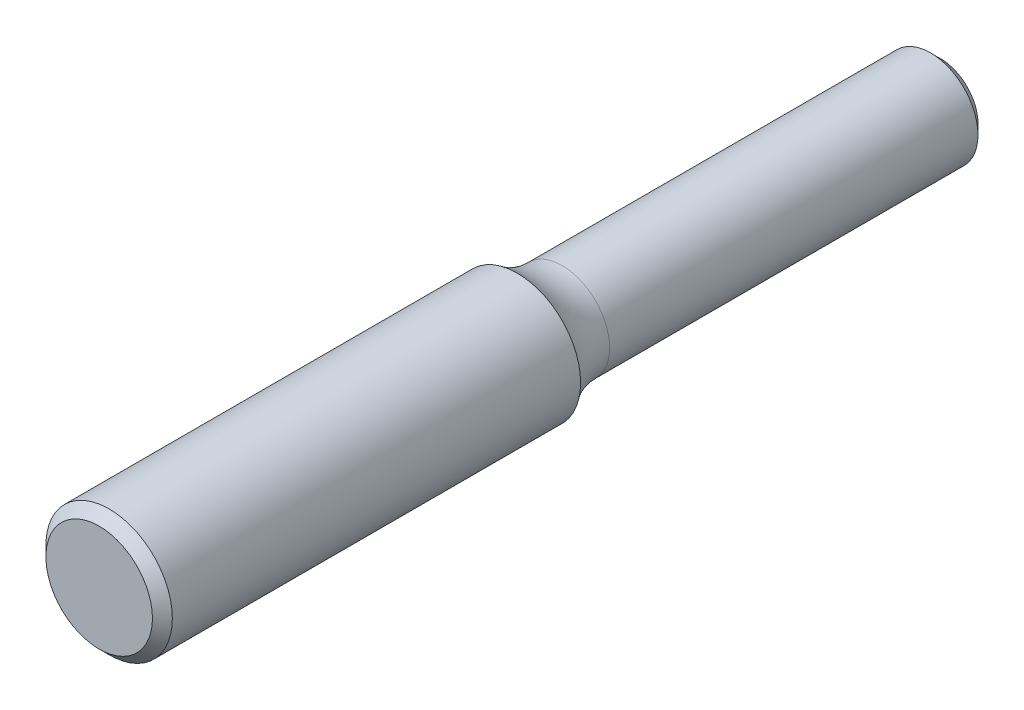
from build123d import *

# Parameters (mm, degrees)
SKETCH2_R           = 3.175
BOSS_EXTRUDE1_DEPTH = 42.25
CHAMFER1_SIZE       = 0.5


with BuildPart() as part:
    # Sketch2 → Boss-Extrude1 (new body)
    with BuildSketch(Plane.XY):
        Circle(SKETCH2_R)
    extrude(amount=BOSS_EXTRUDE1_DEPTH)

    # Sketch5 → Cut-Revolve1 (revolve, cut)
    with BuildSketch(Plane(origin=(0, 0, 0), x_dir=(0, 0, -1), z_dir=(1, 0, 0)), mode=Mode.PRIVATE) as cut_revolve1_sk:
        with BuildLine():
            Line((-21.25, 3.175), (0, 3.175))
            Line((0, 3.175), (0, 2.38125))
            Line((0, 2.38125), (-19, 2.38125))
            ThreePointArc((-19, 2.38125), (-20.192952122, 2.585504811), (-21.25, 3.175))
        make_face()
    revolve(cut_revolve1_sk.sketch.rotate(Axis((0, 0, 21.25), (0, 0, -1)), 90), axis=Axis((0, 0, 21.25), (0, 0, -1)), mode=Mode.SUBTRACT)

    # Chamfer1
    chamfer1_edges = [part.edges().sort_by_distance(p)[0] for p in [
        (-3.175, 0, 42.25),
        (-2.38125, 0, 0),
    ]]
    chamfer(chamfer1_edges, length=CHAMFER1_SIZE)


solid = part.part
